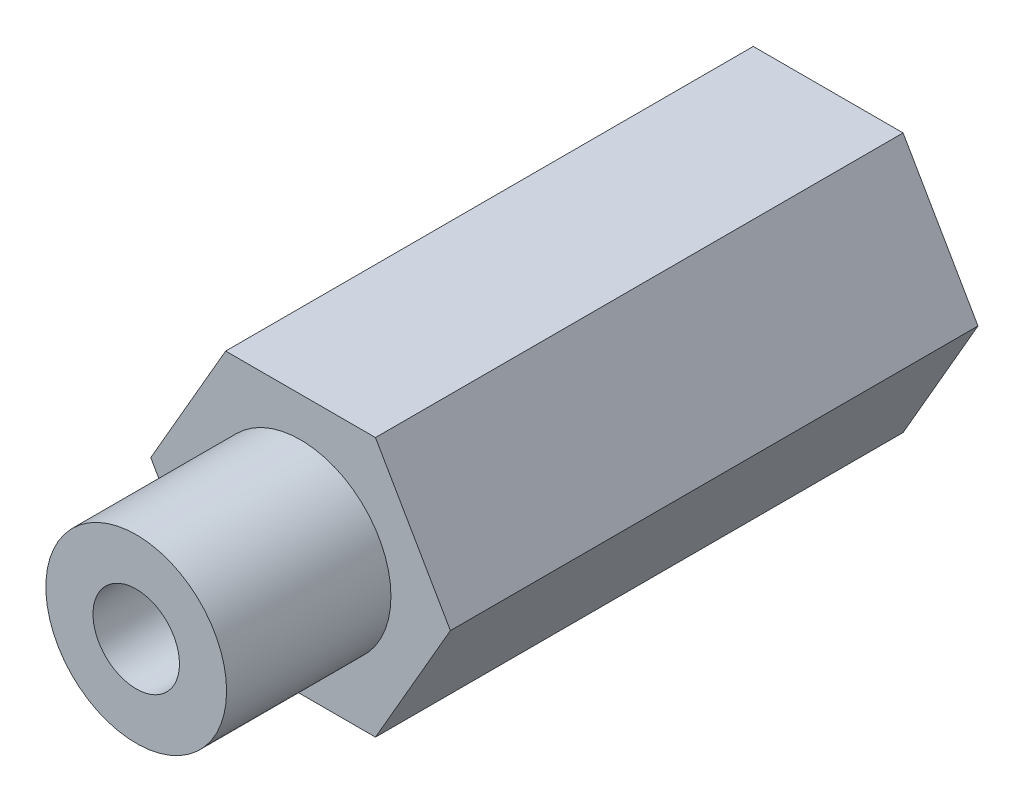
from build123d import *

# Parameters (mm, degrees)
BOSS_EXTRUDE1_DEPTH = 50.8
SKETCH4_R           = 3.175
CUT_EXTRUDE2_DEPTH  = 51.8
SKETCH2_R           = 6.635
CUT_EXTRUDE1_DEPTH  = 12.065
SKETCH3_R           = 6.86
CUT_EXTRUDE3_DEPTH  = 12.065
SKETCH5_R           = 5.145
CUT_EXTRUDE4_DEPTH  = 10


with BuildPart() as part:
    # Sketch1 → Boss-Extrude1 (new body)
    with BuildSketch(Plane(origin=(0, 0, 0), x_dir=(0, 1, 0), z_dir=(0, 0, 1))):
        Polygon((9.525, -5.499261314), (9.525, 5.499261314), (0, 10.998522628), (-9.525, 5.499261314), (-9.525, -5.499261314), (0, -10.998522628), align=None)
    extrude(amount=BOSS_EXTRUDE1_DEPTH)

    # Sketch4 → Cut-Extrude2 (cut, through all)
    with BuildSketch(Plane.XY.offset(50.8)):
        Circle(SKETCH4_R)
    extrude(amount=-CUT_EXTRUDE2_DEPTH, mode=Mode.SUBTRACT)

    # Sketch2 → Cut-Extrude1 (cut)
    with BuildSketch(Plane.XY.offset(50.8)):
        Polygon((10.998522628, 0), (5.499261314, 9.525), (-5.499261314, 9.525), (-10.998522628, 0), (-5.499261314, -9.525), (5.499261314, -9.525), align=None)
        Circle(SKETCH2_R, mode=Mode.SUBTRACT)
    extrude(amount=-CUT_EXTRUDE1_DEPTH, mode=Mode.SUBTRACT)

    # Sketch3 → Cut-Extrude3 (cut)
    with BuildSketch(Plane(origin=(0, 0, 0), x_dir=(1, 0, 0), z_dir=(0, 0, -1))):
        Circle(SKETCH3_R)
    extrude(amount=-CUT_EXTRUDE3_DEPTH, mode=Mode.SUBTRACT)

    # Sketch5 → Cut-Extrude4 (cut)
    with BuildSketch(Plane(origin=(-8.248891971, -4.7625, 0), x_dir=(0.5, -0.866025404, 0), z_dir=(-0.866025404, -0.5, 0))):
        with Locations((0, 19.3675)):
            Circle(SKETCH5_R)
    extrude(amount=-CUT_EXTRUDE4_DEPTH, mode=Mode.SUBTRACT)


solid = part.part
